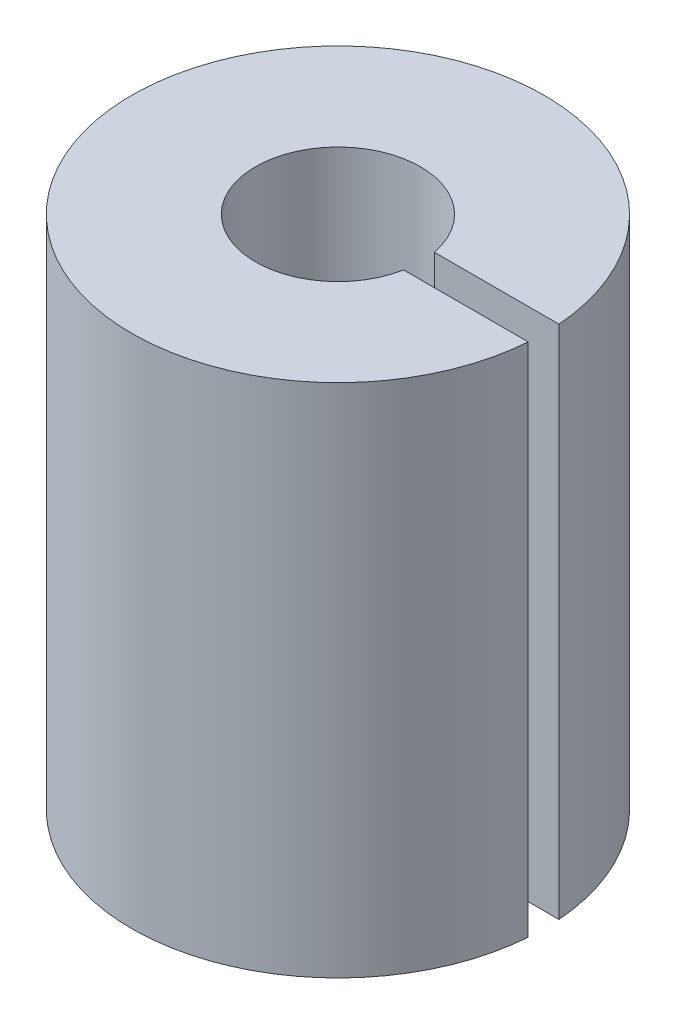
from build123d import *

# Parameters (mm, degrees)
ESQUISSE2_R        = 10
BOSS_EXTRU_1_DEPTH = 25
SKETCH1_R          = 4
CUT_EXTRUDE1_DEPTH = 12.5
SKETCH2_R          = 2.5
CUT_EXTRUDE2_DEPTH = 12.5
SKETCH3_W          = 12.434729812
SKETCH3_H          = 1.489032772
CUT_EXTRUDE3_DEPTH = 25


with BuildPart() as part:
    # Esquisse2 → Boss.-Extru.1 (new body)
    with BuildSketch(Plane(origin=(0, 0, 0), x_dir=(1, 0, 0), z_dir=(0, 1, 0))):
        Circle(ESQUISSE2_R)
    extrude(amount=BOSS_EXTRU_1_DEPTH)

    # Sketch1 → Cut-Extrude1 (cut)
    with BuildSketch(Plane(origin=(0, 25, 0), x_dir=(1, 0, 0), z_dir=(0, 1, 0))):
        Circle(SKETCH1_R)
    extrude(amount=-CUT_EXTRUDE1_DEPTH, mode=Mode.SUBTRACT)

    # Sketch2 → Cut-Extrude2 (cut)
    with BuildSketch(Plane.XZ):
        Circle(SKETCH2_R)
    extrude(amount=-CUT_EXTRUDE2_DEPTH, mode=Mode.SUBTRACT)

    # Sketch3 → Cut-Extrude3 (cut)
    with BuildSketch(Plane(origin=(0, 25, 0), x_dir=(1, 0, 0), z_dir=(0, 1, 0))):
        with Locations((6.217364906, 0)):
            Rectangle(SKETCH3_W, SKETCH3_H)
    extrude(amount=-CUT_EXTRUDE3_DEPTH, mode=Mode.SUBTRACT)


solid = part.part
